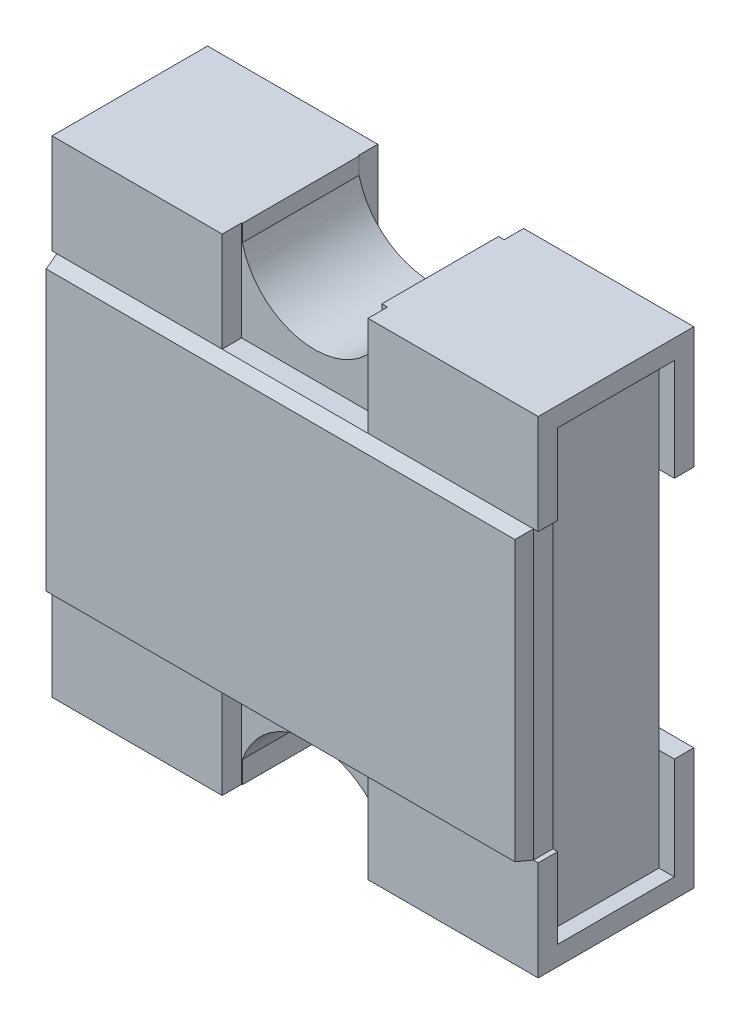
from build123d import *

# Parameters (mm, degrees)
EXTRUDE_START               = 0.04
EXTRUDE_1_DEPTH             = 0.24
EXTRUDE_START_2             = 0.32
SKETCH_2_W                  = 0.98
SKETCH_2_H                  = 0.59
EXTRUDE_1_2_DEPTH           = 0.03
EXTRUDE_1_2_TAPER           = 15
EXTRUDE_1_2_OTHER_WAY_DEPTH = 0.04
EXTRUDE_START_3             = -0.5
EXTRUDE_4_DEPTH             = 0.35
EXTRUDE_START_4             = 0.5
EXTRUDE_5_DEPTH             = 0.35


with BuildPart() as part:
    # Эскиз1 → Extrude 1 (new body)
    with BuildSketch(Plane.XY.offset(EXTRUDE_START)):
        with BuildLine():
            Line((-0.148442184, 0.5), (-0.148442184, 0.465497277))
            ThreePointArc((-0.148442184, 0.465497277), (-0.015030241, 0.35), (0.138400017, 0.437163772))
            Line((0.138400017, 0.437163772), (0.138400017, 0.5))
            Line((0.138400017, 0.5), (0.468400017, 0.5))
            Line((0.468400017, 0.5), (0.468400017, -0.5))
            Line((0.468400017, -0.5), (0.138400017, -0.5))
            Line((0.138400017, -0.5), (0.138400017, -0.432115302))
            ThreePointArc((0.138400017, -0.432115302), (-0.01244424, -0.35), (-0.148442184, -0.454887902))
            Line((-0.148442184, -0.454887902), (-0.148442184, -0.5))
            Line((-0.148442184, -0.5), (-0.478442184, -0.5))
            Line((-0.478442184, -0.5), (-0.478442184, 0.5))
            Line((-0.478442184, 0.5), (-0.148442184, 0.5))
        make_face()
    extrude(amount=EXTRUDE_1_DEPTH)

    # Эскиз2 → Extrude 1 2 (add)
    with BuildSketch(Plane.XY.offset(EXTRUDE_START_2)):
        Rectangle(SKETCH_2_W, SKETCH_2_H)
    extrude(amount=EXTRUDE_1_2_DEPTH, taper=EXTRUDE_1_2_TAPER)

    # Эскиз2 → Extrude 1 2 other way (add)
    with BuildSketch(Plane.XY.offset(EXTRUDE_START_2)):
        Rectangle(SKETCH_2_W, SKETCH_2_H)
    extrude(amount=-EXTRUDE_1_2_OTHER_WAY_DEPTH)

    # Эскиз3<2> → Бобышка-Вытянуть4 (add)
    with BuildSketch(Plane(origin=(0, 0, 0), x_dir=(0, 0, -1), z_dir=(1, 0, 0)).offset(EXTRUDE_START_3)):
        Polygon((-0.32, 0.295), (-0.28, 0.295), (-0.28, 0.46), (-0.04, 0.46), (-0.04, 0.25), (0, 0.25), (0, 0.5), (-0.32, 0.5), align=None)
        Polygon((-0.04, -0.25), (0, -0.25), (0, -0.5), (-0.32, -0.5), (-0.32, -0.295), (-0.28, -0.295), (-0.28, -0.46), (-0.04, -0.46), align=None)
    extrude(amount=EXTRUDE_4_DEPTH)

    # Эскиз3 → Бобышка-Вытянуть5 (add)
    with BuildSketch(Plane(origin=(0, 0, 0), x_dir=(0, 0, -1), z_dir=(1, 0, 0)).offset(EXTRUDE_START_4)):
        Polygon((-0.32, 0.295), (-0.28, 0.295), (-0.28, 0.46), (-0.04, 0.46), (-0.04, 0.25), (0, 0.25), (0, 0.5), (-0.32, 0.5), align=None)
        Polygon((-0.04, -0.25), (0, -0.25), (0, -0.5), (-0.32, -0.5), (-0.32, -0.295), (-0.28, -0.295), (-0.28, -0.46), (-0.04, -0.46), align=None)
    extrude(amount=-EXTRUDE_5_DEPTH)


solid = part.part
